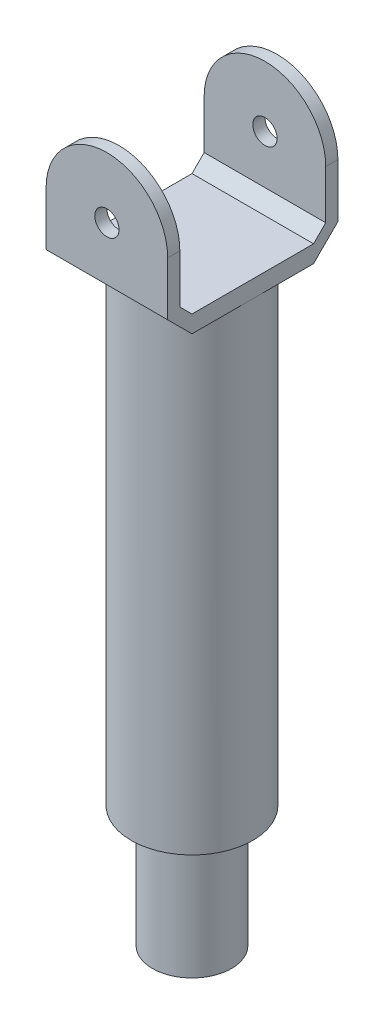
from build123d import *

# Parameters (mm, degrees)
SKETCH1_R               = 32.5
BOSS_EXTRUDE1_DEPTH     = 100
SKETCH2_R               = 50
BOSS_EXTRUDE2_DEPTH     = 400
BOSS_EXTRUDE3_DEPTH     = 50
SKETCH7_R               = 10
CUT_EXTRUDE2_DEPTH      = 1
CUT_EXTRUDE2_DEPTH_BACK = 141


with BuildPart() as part:
    # Sketch1 → Boss-Extrude1 (new body)
    with BuildSketch(Plane(origin=(0, 0, 0), x_dir=(1, 0, 0), z_dir=(0, 1, 0))):
        Circle(SKETCH1_R)
    extrude(amount=BOSS_EXTRUDE1_DEPTH)

    # Sketch2 → Boss-Extrude2 (add)
    with BuildSketch(Plane(origin=(0, 100, 0), x_dir=(1, 0, 0), z_dir=(0, 1, 0))):
        Circle(SKETCH2_R)
    extrude(amount=BOSS_EXTRUDE2_DEPTH)

    # Sketch6 → Boss-Extrude3 (add, symmetric)
    with BuildSketch(Plane(origin=(0, 0, 0), x_dir=(0, 0, -1), z_dir=(1, 0, 0))):
        Polygon((-50, 500), (-60, 510), (-60, 600), (-70, 600), (-70, 505.857864376), (-50, 485.857864376), (50, 485.857864376), (70, 505.857864376), (70, 600), (60, 600), (60, 510), (50, 500), align=None)
    extrude(amount=BOSS_EXTRUDE3_DEPTH, both=True)

    # Sketch7 → Cut-Extrude2 (cut, two sides)
    with BuildSketch(Plane.XY.offset(70)) as cut_extrude2_sk:
        with Locations((0, 550)):
            Circle(SKETCH7_R)
        with BuildLine():
            Line((-50, 550), (-50, 605))
            Line((-50, 605), (50, 605))
            Line((50, 605), (50, 550))
            ThreePointArc((50, 550), (0, 600), (-50, 550))
        make_face()
    extrude(amount=CUT_EXTRUDE2_DEPTH, mode=Mode.SUBTRACT)
    extrude(cut_extrude2_sk.sketch, amount=-CUT_EXTRUDE2_DEPTH_BACK, mode=Mode.SUBTRACT)


solid = part.part
